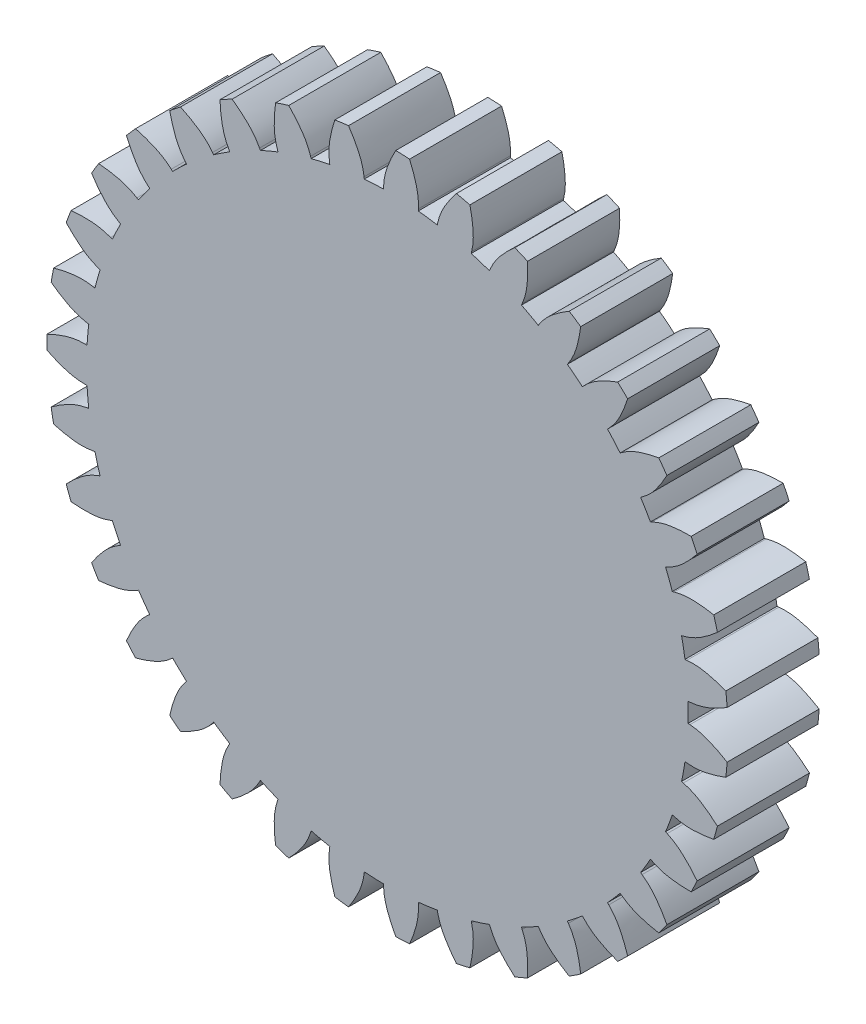
from build123d import *

# Parameters (mm, degrees)
SKETCH12_R        = 16.344686969
CORE_CYL_DEPTH    = 5
TOOTH_EX_DEPTH    = 5
CIRPATTERN1_COUNT = 35


with BuildPart() as part:
    # Sketch12 → core_cyl (new body)
    with BuildSketch(Plane.XY):
        Circle(SKETCH12_R)
    extrude(amount=CORE_CYL_DEPTH)

    # tooth → tooth_ex (add)
    with BuildSketch(Plane.XY):
        with BuildLine():
            add(Edge.make_bspline(
                [(-0.208817168, 16.443295009), (-0.195044102, 17.020569288), (0.049231598, 17.708840373), (0.378596497, 18.353911528), (0.455288893, 18.494396774)],
                knots=[0, 0, 0, 0, 0.507906954, 0.652088785, 0.652088785, 0.652088785, 0.652088785], degree=3))
            Line((-0.208817168, 16.443295009), (-0.213308174, 16.343295009))
            ThreePointArc((-0.213308174, 16.343295009), (0.733301608, 16.328228957), (1.677451127, 16.258380911))
            Line((1.677451127, 16.258380911), (1.681942133, 16.358380911))
            add(Edge.make_bspline(
                [(1.681942133, 16.358380911), (1.719970979, 16.934565861), (1.538374807, 17.641962875), (1.268159566, 18.313961204), (1.204368911, 18.460755551)],
                knots=[0, 0, 0, 0, 0.507906954, 0.652088785, 0.652088785, 0.652088785, 0.652088785], degree=3))
            ThreePointArc((1.204368911, 18.460755551), (0.829999361, 18.481371731), (0.455288893, 18.494396774))
        make_face()
    tooth_ex = extrude(amount=TOOTH_EX_DEPTH)

    # CirPattern1: tooth_ex ×35 about axis
    cirpattern1_axis = Axis((0, 0, 0), (0, 0, 1))
    for i in range(1, CIRPATTERN1_COUNT):
        add(tooth_ex.rotate(cirpattern1_axis, i * 360 / CIRPATTERN1_COUNT))


solid = part.part
